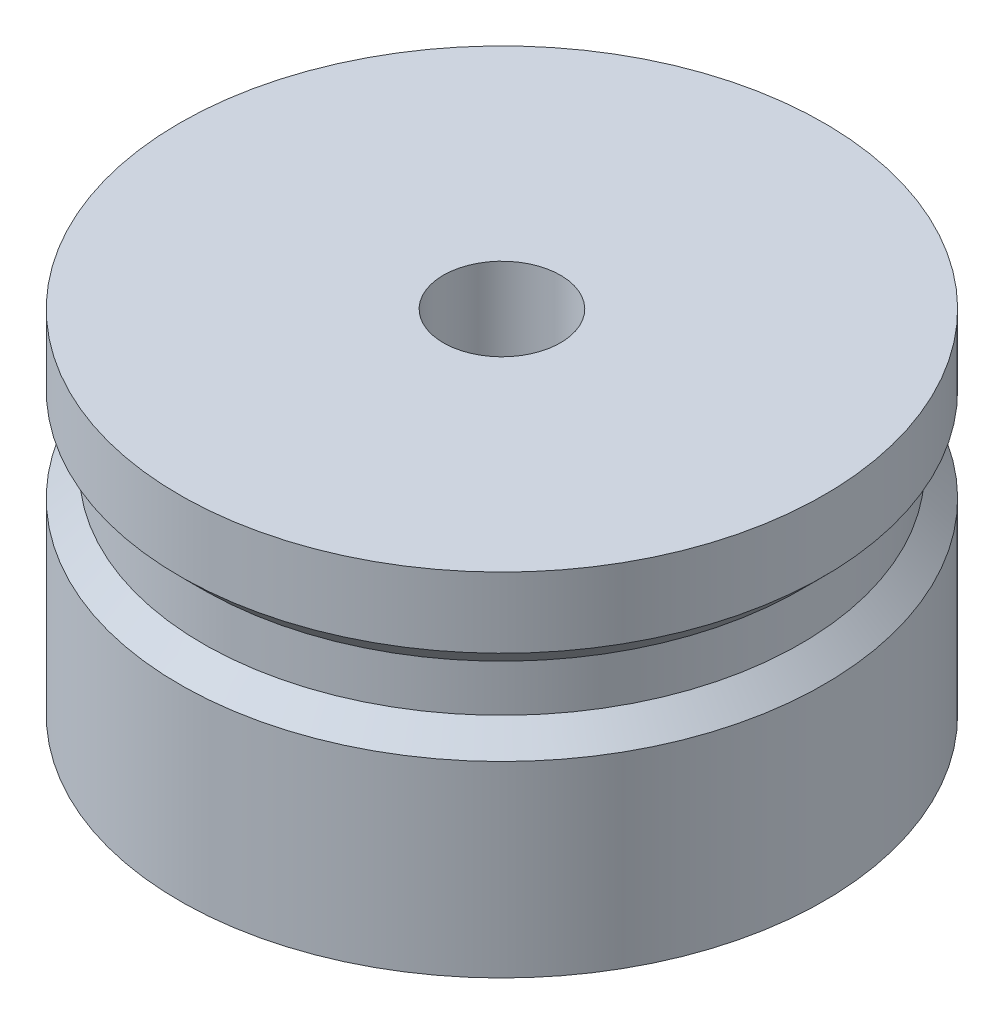
from build123d import *


with BuildPart() as part:
    # Esboço1 → Revolução1 (revolve)
    with BuildSketch(Plane.XY, mode=Mode.PRIVATE) as revolu_o1_sk:
        Polygon((5, 0), (5, -30), (27.5, -30), (27.5, -14), (25.5, -12), (25.5, -8), (27.5, -6), (27.5, 0), align=None)
    revolve(revolu_o1_sk.sketch.rotate(Axis((0, 0, 0), (0, -1, 0)), 180), axis=Axis((0, 0, 0), (0, -1, 0)))  # turned: the seam where the file's is


solid = part.part
